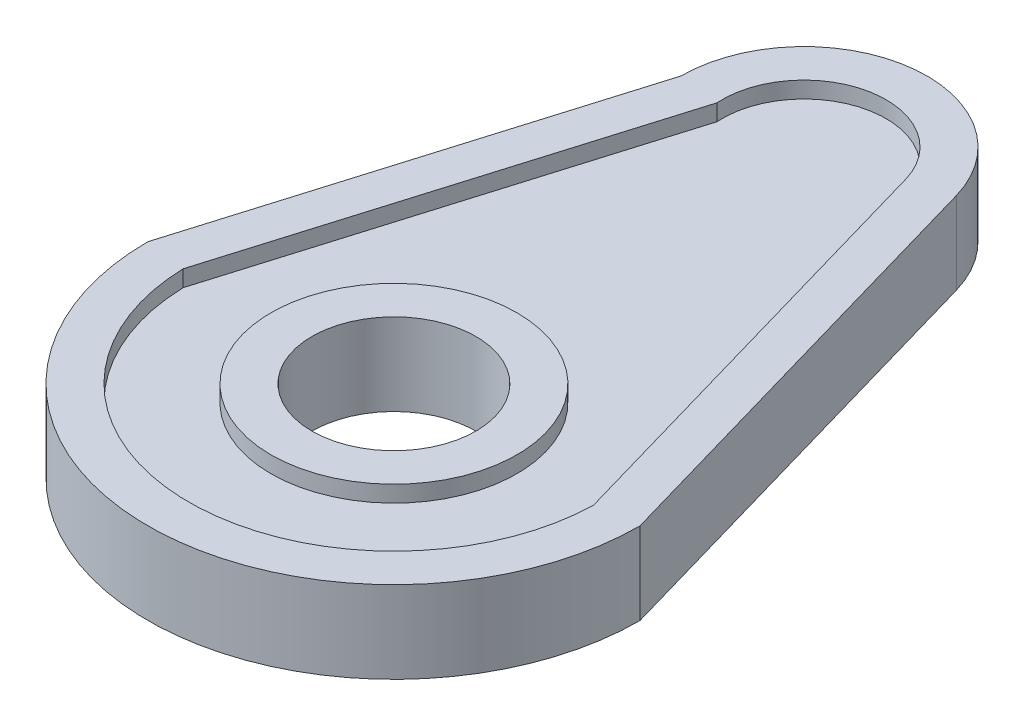
from build123d import *

# Parameters (mm, degrees)
BOSS_EXTRUDE1_DEPTH = 5
CUT_EXTRUDE1_DEPTH  = 2
SKETCH3_R           = 10
CUT_EXTRUDE2_DEPTH  = 9
SKETCH4_R           = 15
SKETCH4_R_2         = 10
BOSS_EXTRUDE2_DEPTH = 2


with BuildPart() as part:
    # Sketch1 → Boss-Extrude1 (new body, symmetric)
    with BuildSketch(Plane(origin=(0, 0, 0), x_dir=(1, 0, 0), z_dir=(0, 1, 0))):
        with BuildLine():
            ThreePointArc((14.41480993, 54.148885958), (-2.094976259, 64.852982006), (-15, 50))
            Line((-15, 50), (-30, 0))
            ThreePointArc((-30, 0), (0, -30), (30, 0))
            Line((30, 0), (14.41480993, 54.148885958))
        make_face()
    extrude(amount=BOSS_EXTRUDE1_DEPTH, both=True)

    # Sketch2 → Cut-Extrude1 (cut)
    with BuildSketch(Plane(origin=(0, 5, 0), x_dir=(1, 0, 0), z_dir=(0, 1, 0))):
        with BuildLine():
            Line((24.99092108, -0.673693969), (9.609873286, 52.765923972))
            ThreePointArc((9.609873286, 52.765923972), (-1.723304272, 59.850391992), (-9.978133058, 49.339045626))
            Line((-9.978133058, 49.339045626), (-24.990168055, -0.701071031))
            ThreePointArc((-24.990168055, -0.701071031), (0.013693708, -24.99999625), (24.99092108, -0.673693969))
        make_face()
    cut_extrude1 = extrude(amount=-CUT_EXTRUDE1_DEPTH, mode=Mode.SUBTRACT)

    # Mirror1: Cut-Extrude1 across plane
    add(cut_extrude1.mirror(Plane.ZX), mode=Mode.SUBTRACT)

    # Sketch3 → Cut-Extrude2 (cut, through all)
    with BuildSketch(Plane(origin=(0, 3, 0), x_dir=(1, 0, 0), z_dir=(0, 1, 0))):
        Circle(SKETCH3_R)
    extrude(amount=-CUT_EXTRUDE2_DEPTH, mode=Mode.SUBTRACT)

    # Sketch4 → Boss-Extrude2 (add)
    with BuildSketch(Plane(origin=(0, 3, 0), x_dir=(1, 0, 0), z_dir=(0, 1, 0))):
        Circle(SKETCH4_R)
        Circle(SKETCH4_R_2, mode=Mode.SUBTRACT)
    boss_extrude2 = extrude(amount=BOSS_EXTRUDE2_DEPTH)

    # Mirror2: Boss-Extrude2 across plane
    add(boss_extrude2.mirror(Plane.ZX))


solid = part.part
